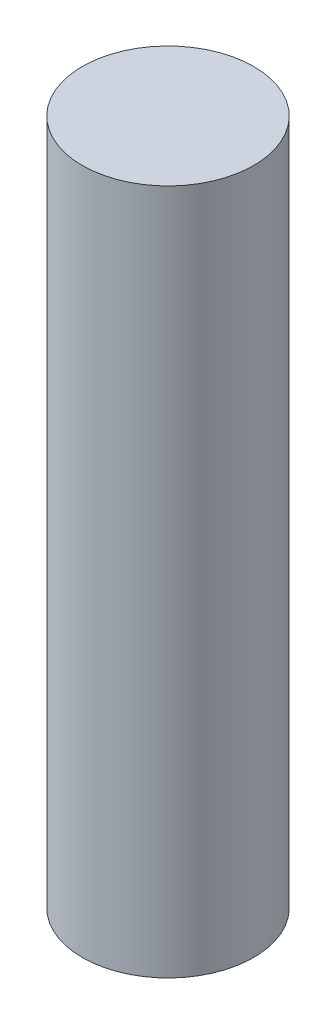
from build123d import *

# Parameters (mm, degrees)
SKETCH1_R           = 15.875
BOSS_EXTRUDE1_DEPTH = 127


with BuildPart() as part:
    # Sketch1 → Boss-Extrude1 (new body)
    with BuildSketch(Plane(origin=(0, 0, 0), x_dir=(1, 0, 0), z_dir=(0, 1, 0))):
        Circle(SKETCH1_R)
    extrude(amount=BOSS_EXTRUDE1_DEPTH)


solid = part.part
